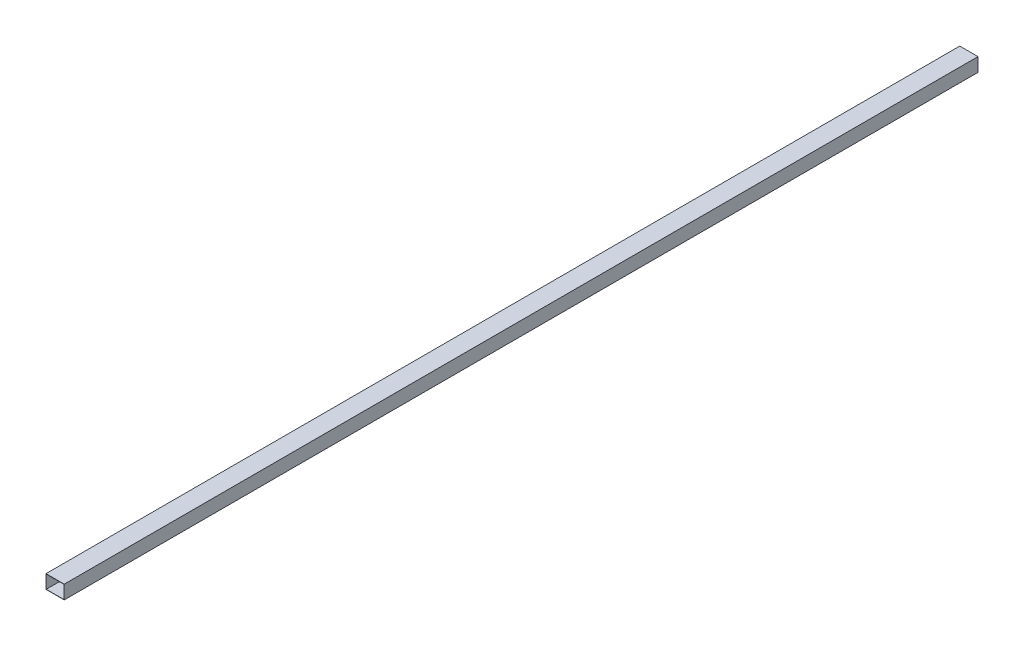
from build123d import *

# Parameters (mm, degrees)
SCHIZZO1_W                   = 40
SCHIZZO1_H                   = 30
SCHIZZO1_W_2                 = 39
SCHIZZO1_H_2                 = 29
ESTRUSIONE_ESTRUSIONE1_DEPTH = 2004


with BuildPart() as part:
    # Schizzo1 → Estrusione-Estrusione1 (new body)
    with BuildSketch(Plane.XY):
        Rectangle(SCHIZZO1_W, SCHIZZO1_H)
        Rectangle(SCHIZZO1_W_2, SCHIZZO1_H_2, mode=Mode.SUBTRACT)
    extrude(amount=ESTRUSIONE_ESTRUSIONE1_DEPTH)


solid = part.part
